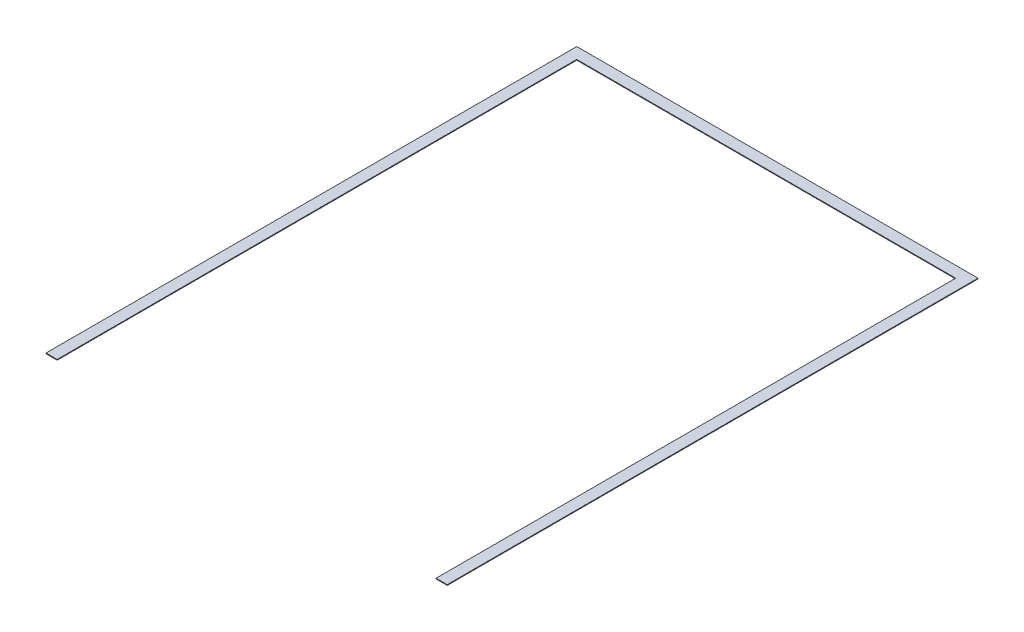
from build123d import *

# Parameters (mm, degrees)
BOSS_EXTRUDE1_DEPTH = 3.175


with BuildPart() as part:
    # Sketch1 → Boss-Extrude1 (new body)
    with BuildSketch(Plane(origin=(0, 0, 0), x_dir=(1, 0, 0), z_dir=(0, 1, 0))):
        Polygon((-914.4, -2419.35), (-914.4, 0), (914.4, 0), (914.4, -2419.35), (863.6, -2419.35), (863.6, -50.8), (-863.6, -50.8), (-863.6, -2419.35), align=None)
    extrude(amount=BOSS_EXTRUDE1_DEPTH)


solid = part.part
